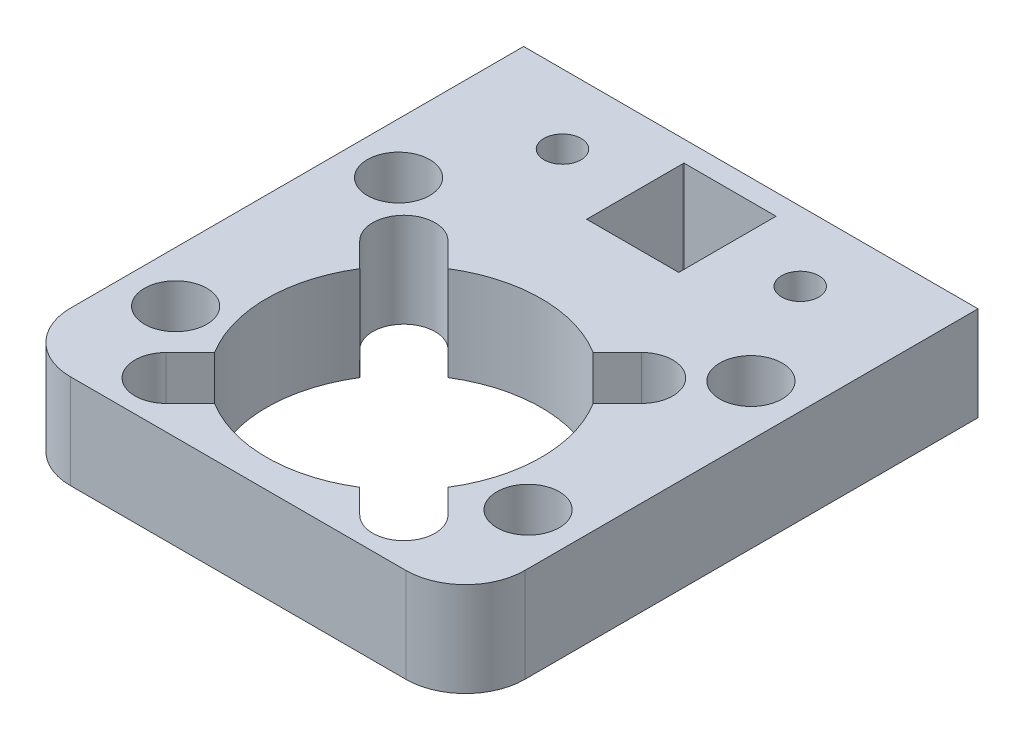
from build123d import *

# Parameters (mm, degrees)
BOSS_EXTRUDE1_DEPTH            = 6.35
CUT_EXTRUDE1_DEPTH             = 7.35
F_2_5_2_5_DIAMETER_HOLE1_D     = 2.5
F_2_5_2_5_DIAMETER_HOLE1_DEPTH = 6.35
F_2_5_2_5_DIAMETER_HOLE2_D     = 2.5
F_2_5_2_5_DIAMETER_HOLE2_DEPTH = 6.35
F_4_2_4_2_DIAMETER_HOLE1_D     = 4.2
F_4_2_4_2_DIAMETER_HOLE1_DEPTH = 6.35
F_4_2_4_2_DIAMETER_HOLE2_D     = 4.2
F_4_2_4_2_DIAMETER_HOLE2_DEPTH = 6.35
F_4_2_4_2_DIAMETER_HOLE3_D     = 4.2
F_4_2_4_2_DIAMETER_HOLE3_DEPTH = 6.35
F_4_2_4_2_DIAMETER_HOLE4_D     = 4.2
F_4_2_4_2_DIAMETER_HOLE4_DEPTH = 6.35


with BuildPart() as part:
    # Sketch1 → Boss-Extrude1 (new body)
    with BuildSketch(Plane(origin=(0, 6.35, 0), x_dir=(1, 0, 0), z_dir=(0, 1, 0))):
        with BuildLine():
            Line((-15.289019905, 23.35), (-15.289019905, -7.15))
            ThreePointArc((-15.289019905, -7.15), (-14.11744703, -9.978427125), (-11.289019905, -11.15))
            Line((-11.289019905, -11.15), (11.288980095, -11.15))
            ThreePointArc((11.288980095, -11.15), (14.11740722, -9.978427125), (15.288980095, -7.15))
            Line((15.288980095, -7.15), (15.288980095, 23.35))
            Line((15.288980095, 23.35), (-15.289019905, 23.35))
        make_face()
        Polygon((-3.100095833, 15.4), (-3.100019905, 15.499999999), (-3.100019905, 21.85), (-3.09998206, 21.949999993), (3.099980095, 21.947653655), (3.099980095, 15.500000006), (3.100055965, 15.4), align=None, mode=Mode.SUBTRACT)
    extrude(amount=-BOSS_EXTRUDE1_DEPTH)

    # Sketch2 → Cut-Extrude1 (cut, through all)
    with BuildSketch(Plane.XZ):
        with BuildLine():
            Line((4.885014967, -7.854879297), (6.515054007, -9.484922393))
            ThreePointArc((6.515054007, -9.484922393), (9.484902488, -9.484926088), (9.484906183, -6.515077607))
            Line((9.484906183, -6.515077607), (7.854867143, -4.885034511))
            ThreePointArc((7.854867143, -4.885034511), (9.25, 0), (7.854867143, 4.885034511))
            Line((7.854867143, 4.885034511), (9.484906183, 6.515077607))
            ThreePointArc((9.484906183, 6.515077607), (9.484902486, 9.484926095), (6.515053997, 9.484922394))
            Line((6.515053997, 9.484922394), (4.885014967, 7.854879297))
            ThreePointArc((4.885014967, 7.854879297), (-1.1508e-05, 9.25), (-4.885034511, 7.854867143))
            Line((-4.885034511, 7.854867143), (-6.515097512, 9.484926088))
            ThreePointArc((-6.515097512, 9.484926088), (-9.484946, 9.484922391), (-9.484942299, 6.515073902))
            Line((-9.484942299, 6.515073902), (-7.854879297, 4.885014967))
            ThreePointArc((-7.854879297, 4.885014967), (-9.25, 0), (-7.854879297, -4.885014967))
            Line((-7.854879297, -4.885014967), (-9.484942298, -6.515073912))
            ThreePointArc((-9.484942298, -6.515073912), (-9.484945993, -9.484922393), (-6.515097512, -9.484926088))
            Line((-6.515097512, -9.484926088), (-4.885034511, -7.854867143))
            ThreePointArc((-4.885034511, -7.854867143), (-1.1508e-05, -9.25), (4.885014967, -7.854879297))
        make_face()
    extrude(amount=-CUT_EXTRUDE1_DEPTH, mode=Mode.SUBTRACT)

    # Ø2.5 (2.5) Diameter Hole1
    with Locations(Plane(origin=(0, 0, 0), x_dir=(-1, 0, 0), z_dir=(0, -1, 0))):
        with Locations((8.000019905, 18.675)):
            Hole(F_2_5_2_5_DIAMETER_HOLE1_D / 2, depth=F_2_5_2_5_DIAMETER_HOLE1_DEPTH)

    # Ø2.5 (2.5) Diameter Hole2
    with Locations(Plane(origin=(0, 0, 0), x_dir=(-1, 0, 0), z_dir=(0, -1, 0))):
        with Locations((-7.999980095, 18.675)):
            Hole(F_2_5_2_5_DIAMETER_HOLE2_D / 2, depth=F_2_5_2_5_DIAMETER_HOLE2_DEPTH)

    # Ø4.2 (4.2) Diameter Hole1
    with Locations(Plane(origin=(0, 0, 0), x_dir=(-1, 0, 0), z_dir=(0, -1, 0))):
        with Locations((-11.858647005, 11.5)):
            Hole(F_4_2_4_2_DIAMETER_HOLE1_D / 2, depth=F_4_2_4_2_DIAMETER_HOLE1_DEPTH)

    # Ø4.2 (4.2) Diameter Hole2
    with Locations(Plane(origin=(0, 0, 0), x_dir=(-1, 0, 0), z_dir=(0, -1, 0))):
        with Locations((11.858637076, 11.5)):
            Hole(F_4_2_4_2_DIAMETER_HOLE2_D / 2, depth=F_4_2_4_2_DIAMETER_HOLE2_DEPTH)

    # Ø4.2 (4.2) Diameter Hole3
    with Locations(Plane(origin=(0, 0, 0), x_dir=(-1, 0, 0), z_dir=(0, -1, 0))):
        with Locations((-11.859575542, -3.5)):
            Hole(F_4_2_4_2_DIAMETER_HOLE3_D / 2, depth=F_4_2_4_2_DIAMETER_HOLE3_DEPTH)

    # Ø4.2 (4.2) Diameter Hole4
    with Locations(Plane(origin=(0, 0, 0), x_dir=(-1, 0, 0), z_dir=(0, -1, 0))):
        with Locations((11.85956559, -3.500033723)):
            Hole(F_4_2_4_2_DIAMETER_HOLE4_D / 2, depth=F_4_2_4_2_DIAMETER_HOLE4_DEPTH)


solid = part.part
